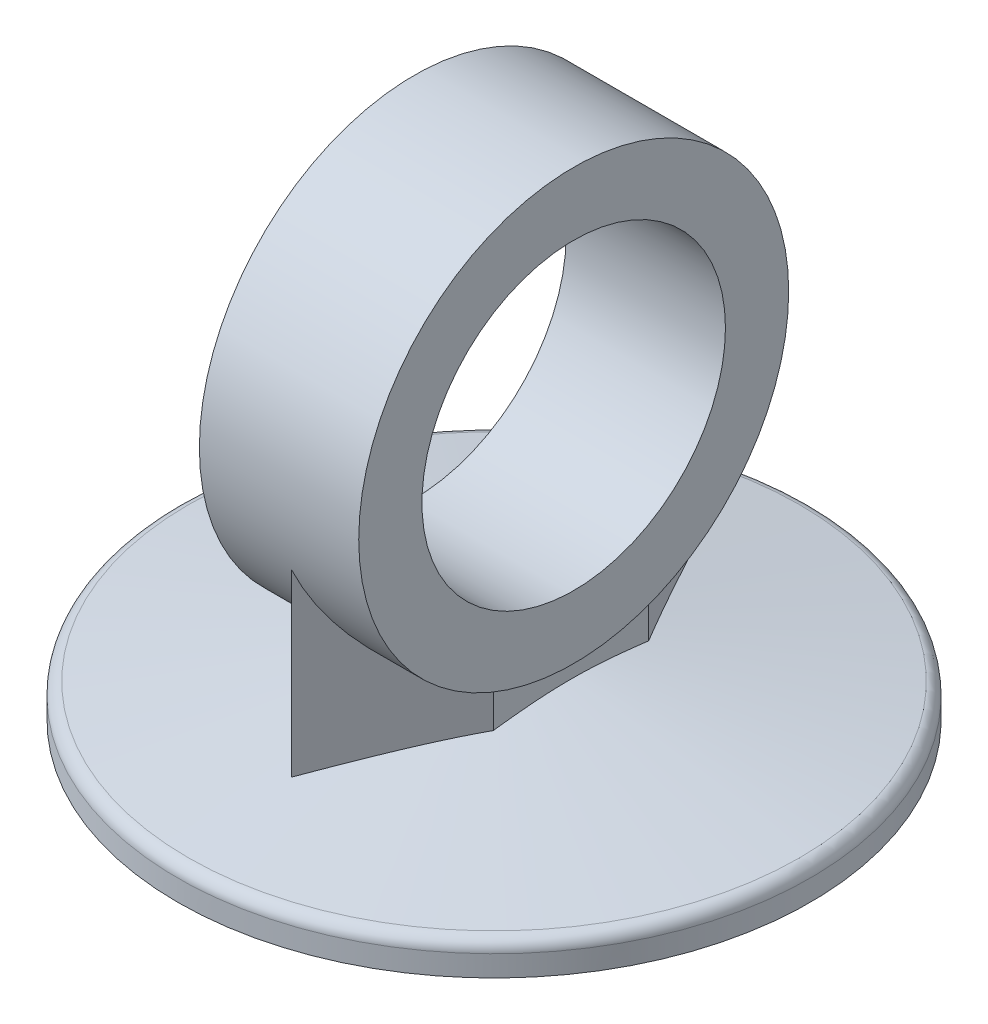
from build123d import *

# Parameters (mm, degrees)
SKETCH1_R                 = 25
BOSS_EXTRUDE1_DEPTH       = 2.5
FILLET1_R                 = 1
BOSS_EXTRUDE9_DEPTH       = 15
BOSS_EXTRUDE11_DEPTH      = 6.3
BOSS_EXTRUDE11_DEPTH_BACK = 6.3
SKETCH5_R                 = 17
CUT_EXTRUDE3_DEPTH        = 6.3
CUT_EXTRUDE3_DEPTH_BACK   = 6.3
SKETCH6_R                 = 12


with BuildPart() as part:
    # Sketch1 → Boss-Extrude1 (new body)
    with BuildSketch(Plane(origin=(0, 0, 0), x_dir=(1, 0, 0), z_dir=(0, 1, 0))):
        with Locations(Location((0, 0, 0), (0, 0, 270))):
            Circle(SKETCH1_R)
    extrude(amount=BOSS_EXTRUDE1_DEPTH)

    # Boss-Extrude3 cone 1 section (through the dimple's axis) → Boss-Extrude3 (revolve)
    with BuildSketch(Plane(origin=(0, 2.5, 0), x_dir=(0, 0, -1), z_dir=(1, 0, 0))):
        Polygon((0, 0), (25, 0), (0, 4.408174518), align=None)
    revolve(axis=Axis((0, 2.5, 0), (0, 1, 0)))

    # Fillet1
    fillet1_edges = [part.edges().sort_by_distance(p)[0] for p in [
        (-25, 2.5, 0),
    ]]
    fillet(fillet1_edges, radius=FILLET1_R)

    # Sketch4 → Boss-Extrude9 (add)
    with BuildSketch(Plane(origin=(0, 4, 0), x_dir=(-1, 0, 0), z_dir=(0, 1, 0))):
        Polygon((-6.085829464, 6.143185176), (0, 16.013255457), (6.085829464, 6.143185176), (6.085829464, -6.143185176), (0, -16.013255457), (-6.085829464, -6.143185176), align=None)
    extrude(amount=BOSS_EXTRUDE9_DEPTH)

    # Sketch5 → Boss-Extrude11 (add, two sides: drawn at the far end of the back side and taken through both)
    with BuildSketch(Plane(origin=(0, 0, 0), x_dir=(0, 0, -1), z_dir=(1, 0, 0)).offset(-BOSS_EXTRUDE11_DEPTH_BACK)):
        with Locations((0, 24)):
            Circle(SKETCH5_R)
    extrude(amount=BOSS_EXTRUDE11_DEPTH + BOSS_EXTRUDE11_DEPTH_BACK)

    # Sketch6 → Cut-Extrude3 (cut, two sides: drawn at the far end of the back side and taken through both)
    with BuildSketch(Plane(origin=(0, 0, 0), x_dir=(0, 0, -1), z_dir=(1, 0, 0)).offset(-CUT_EXTRUDE3_DEPTH_BACK)):
        with Locations((0, 24)):
            Circle(SKETCH6_R)
    extrude(amount=CUT_EXTRUDE3_DEPTH + CUT_EXTRUDE3_DEPTH_BACK, mode=Mode.SUBTRACT)


solid = part.part
